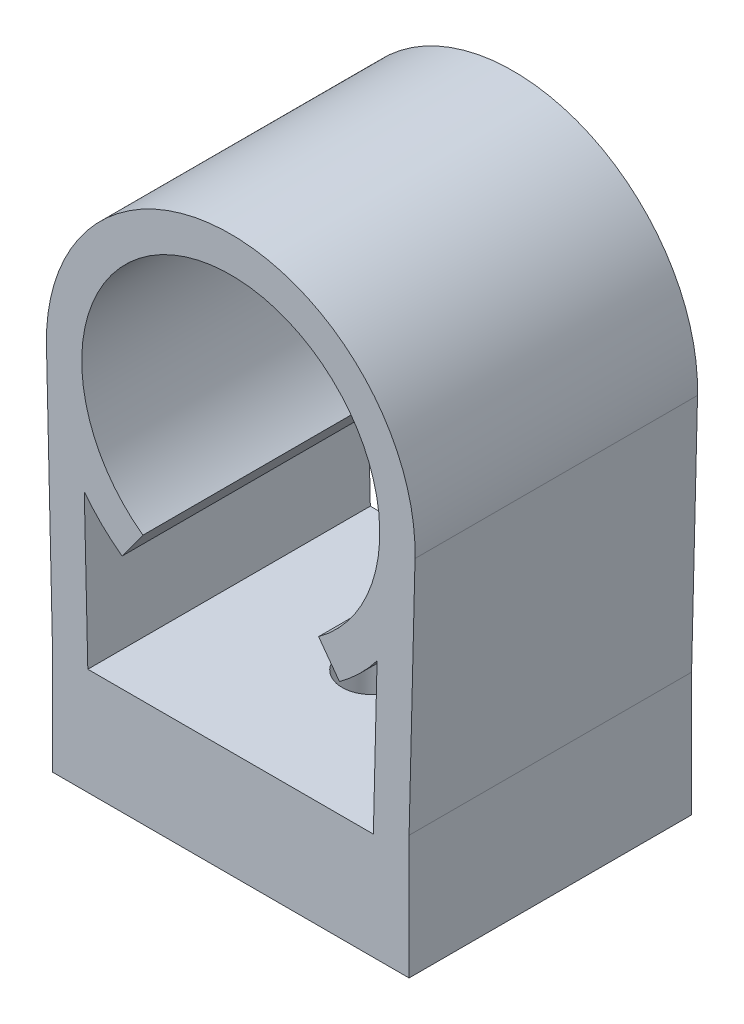
from build123d import *

# Parameters (mm, degrees)
BOSS_EXTRUDE1_DEPTH       = 20.32
F_8_CLEARANCE_HOLE1_D     = 4.3053
F_8_CLEARANCE_HOLE1_DEPTH = 7.679166788


with BuildPart() as part:
    # Sketch1 → Boss-Extrude1 (new body)
    with BuildSketch(Plane.XY):
        with BuildLine():
            Line((0, 0), (25.654, 0))
            Line((25.654, 0), (25.654, 8.89))
            Line((25.654, 8.89), (26.081819356, 26.345128821))
            ThreePointArc((26.081819356, 26.345128821), (12.835928023, 39.928796994), (-0.42824485, 26.362979796))
            Line((-0.42824485, 26.362979796), (0, 7.874))
            Line((0, 7.874), (0, 0))
        make_face()
        with BuildLine():
            Line((2.545194005, 7.679166788), (23.083560079, 7.679166788))
            Line((23.083560079, 7.679166788), (23.351364853, 18.605663581))
            ThreePointArc((23.351364853, 18.605663581), (22.092748432, 17.18624107), (20.64444443, 15.960969231))
            Line((20.64444443, 15.960969231), (19.146849712, 18.012507692))
            ThreePointArc((19.146849712, 18.012507692), (12.827, 37.3888), (6.507150288, 18.012507692))
            Line((6.507150288, 18.012507692), (5.00955557, 15.960969231))
            ThreePointArc((5.00955557, 15.960969231), (3.55486763, 17.192482458), (2.291784196, 18.619844386))
            Line((2.291784196, 18.619844386), (2.545194005, 7.679166788))
        make_face(mode=Mode.SUBTRACT)
    extrude(amount=BOSS_EXTRUDE1_DEPTH)

    # #8 Clearance Hole1
    with Locations(Plane(origin=(0, 0, 0), x_dir=(-1, 0, 0), z_dir=(0, -1, 0))):
        with Locations((-12.827, -10.16)):
            Hole(F_8_CLEARANCE_HOLE1_D / 2, depth=F_8_CLEARANCE_HOLE1_DEPTH)


solid = part.part
